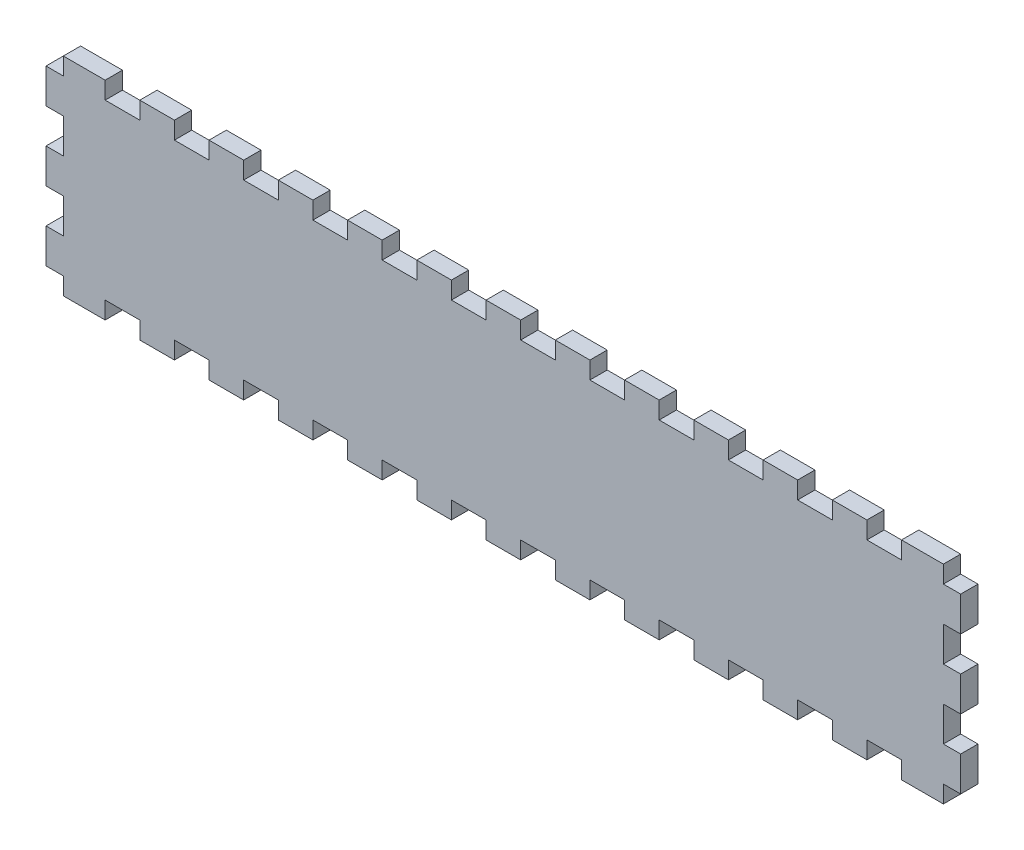
from build123d import *

# Parameters (mm, degrees)
BOSS_EXTRUDE5_DEPTH = 6


with BuildPart() as part:
    # Sketch2 → Boss-Extrude5 (new body)
    with BuildSketch(Plane.XY):
        Polygon((-152.5, 6), (-152.5, 0), (-158.5, 0), (-158.5, -12), (-152.5, -12), (-152.5, -24), (-158.5, -24), (-158.5, -36), (-152.5, -36), (-152.5, -48), (-158.5, -48), (-158.5, -60), (-152.5, -60), (-152.5, -66), (-138, -66), (-138, -60), (-126, -60), (-126, -66), (-114, -66), (-114, -60), (-102, -60), (-102, -66), (-90, -66), (-90, -60), (-78, -60), (-78, -66), (-66, -66), (-66, -60), (-54, -60), (-54, -66), (-42, -66), (-42, -60), (-30, -60), (-30, -66), (-18, -66), (-18, -60), (-6, -60), (-6, -66), (6, -66), (6, -60), (18, -60), (18, -66), (30, -66), (30, -60), (42, -60), (42, -66), (54, -66), (54, -60), (66, -60), (66, -66), (78, -66), (78, -60), (90, -60), (90, -66), (102, -66), (102, -60), (114, -60), (114, -66), (126, -66), (126, -60), (138, -60), (138, -66), (152.5, -66), (152.5, -60), (158.5, -60), (158.5, -48), (152.5, -48), (152.5, -36), (158.5, -36), (158.5, -24), (152.5, -24), (152.5, -12), (158.5, -12), (158.5, 0), (152.5, 0), (152.5, 6), (138, 6), (138, 0), (126, 0), (126, 6), (114, 6), (114, 0), (102, 0), (102, 6), (90, 6), (90, 0), (78, 0), (78, 6), (66, 6), (66, 0), (54, 0), (54, 6), (42, 6), (42, 0), (30, 0), (30, 6), (18, 6), (18, 0), (6, 0), (6, 6), (-6, 6), (-6, 0), (-18, 0), (-18, 6), (-30, 6), (-30, 0), (-42, 0), (-42, 6), (-54, 6), (-54, 0), (-66, 0), (-66, 6), (-78, 6), (-78, 0), (-90, 0), (-90, 6), (-102, 6), (-102, 0), (-114, 0), (-114, 6), (-126, 6), (-126, 0), (-138, 0), (-138, 6), align=None)
    extrude(amount=BOSS_EXTRUDE5_DEPTH)


solid = part.part
